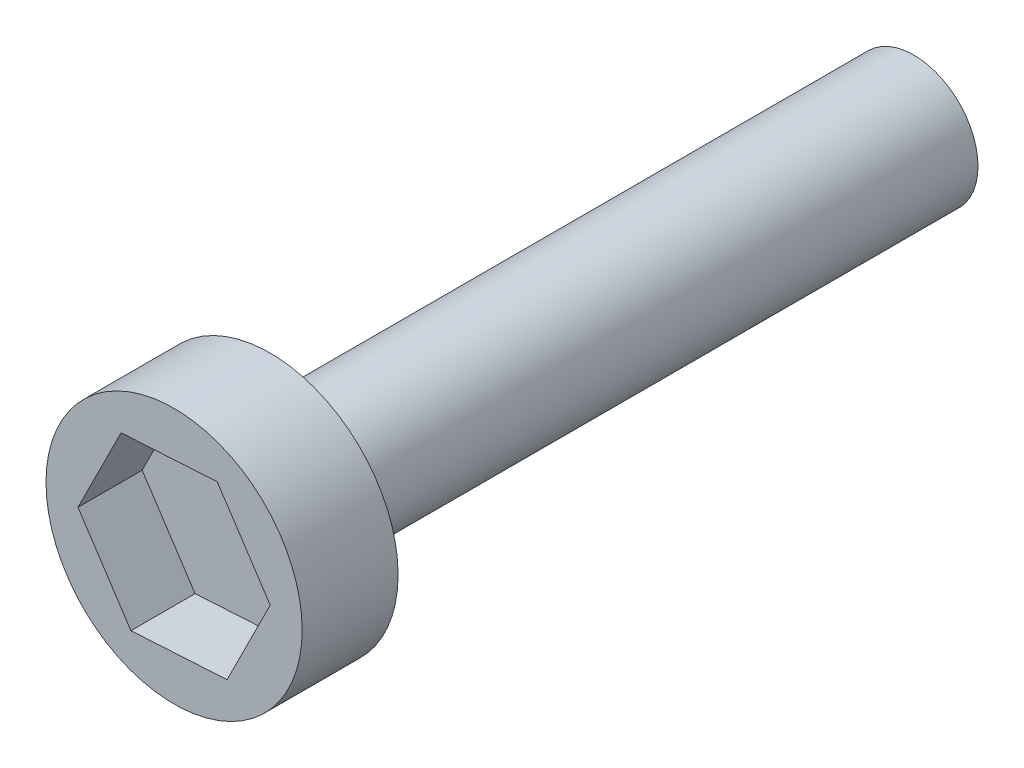
from build123d import *

# Parameters (mm, degrees)
SKETCH1_R           = 12.699809316
BOSS_EXTRUDE1_DEPTH = 127
SKETCH3_W           = 18.981342934
SKETCH3_H           = 25.339659509
CUT_EXTRUDE1_DEPTH  = 12.7


with BuildPart() as part:
    # Sketch1 → Boss-Extrude1 (new body)
    with BuildSketch(Plane.XY):
        Circle(SKETCH1_R)
    extrude(amount=BOSS_EXTRUDE1_DEPTH)


with BuildPart() as body_2:
    # Sketch3 → Revolve1 (revolve)
    with BuildSketch(Plane(origin=(0, 0, 0), x_dir=(0, 0, -1), z_dir=(1, 0, 0))):
        with Locations((-136.855411879, 12.669829755)):
            Rectangle(SKETCH3_W, SKETCH3_H)
    revolve(axis=Axis((0, 0, 127.364740412), (0, 0, 1)))

    # Sketch4 → Cut-Extrude1 (cut)
    with BuildSketch(Plane.XY.offset(146.346083346)):
        Polygon((8.53807174, 17.029498846), (-10.478942745, 15.908936449), (-19.017014485, -1.120562397), (-8.53807174, -17.029498846), (10.478942745, -15.908936449), (19.017014485, 1.120562397), align=None)
    extrude(amount=-CUT_EXTRUDE1_DEPTH, mode=Mode.SUBTRACT)


solid = Compound([part.part, body_2.part])
